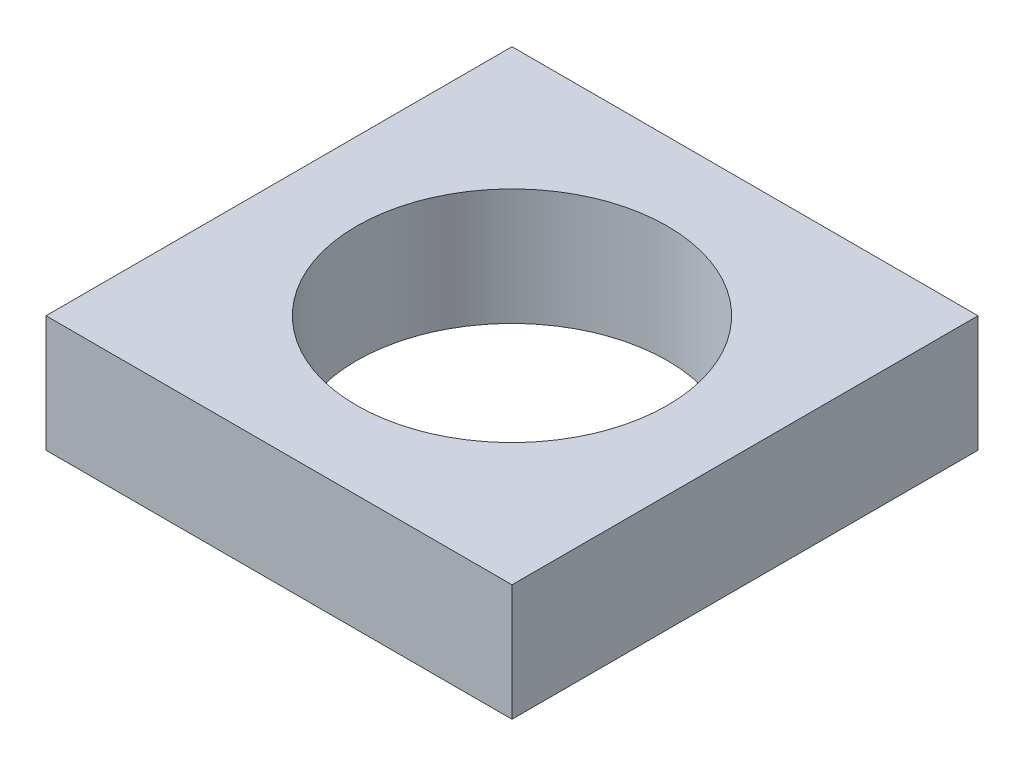
from build123d import *

# Parameters (mm, degrees)
SKETCH1_W           = 12
SKETCH1_H           = 12
SKETCH1_R           = 4
BOSS_EXTRUDE2_DEPTH = 3


with BuildPart() as part:
    # Sketch1 → Boss-Extrude2 (new body)
    with BuildSketch(Plane(origin=(0, 0, 0), x_dir=(1, 0, 0), z_dir=(0, 1, 0))):
        Rectangle(SKETCH1_W, SKETCH1_H)
        Circle(SKETCH1_R, mode=Mode.SUBTRACT)
    extrude(amount=BOSS_EXTRUDE2_DEPTH)


solid = part.part
